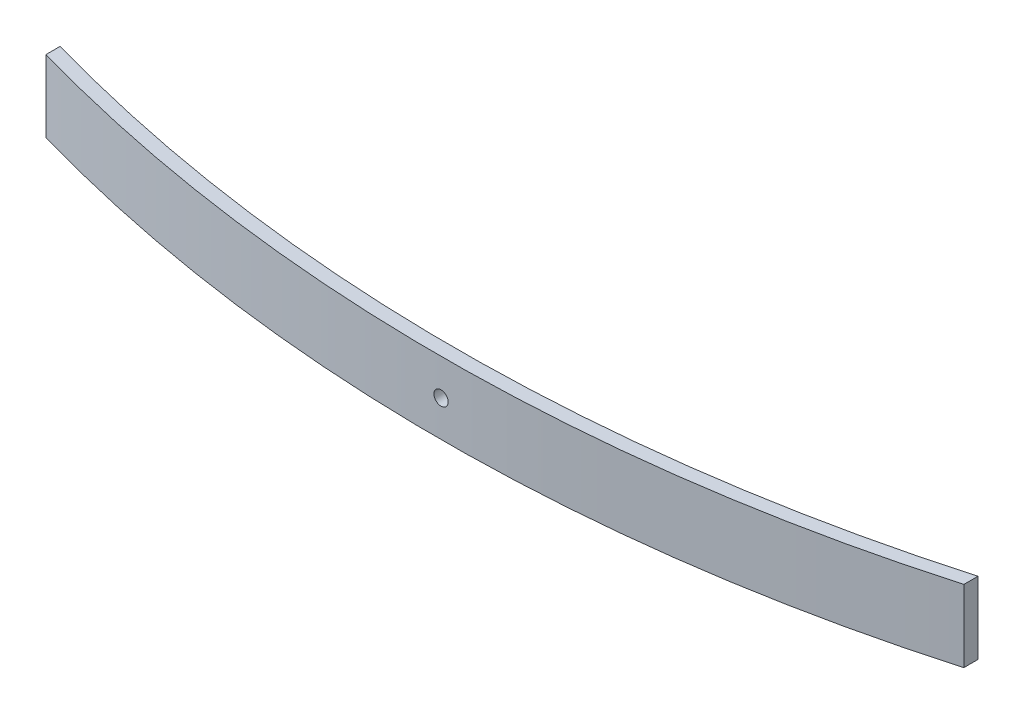
from build123d import *

# Parameters (mm, degrees)
BOSS_EXTRUDE1_DEPTH = 76.2
SKETCH9_R           = 7.5
CUT_EXTRUDE1_DEPTH  = 209


with BuildPart() as part:
    # Sketch1 → Boss-Extrude1 (new body)
    with BuildSketch(Plane(origin=(0, 0, 0), x_dir=(1, 0, 0), z_dir=(0, 1, 0))):
        with BuildLine():
            ThreePointArc((485.021699517, -125.489595812), (0, -193), (-485.021699517, -125.489595812))
            Line((-485.021699517, -125.489595812), (-485.021699517, -140.489595812))
            ThreePointArc((-485.021699517, -140.489595812), (0, -208), (485.021699517, -140.489595812))
            Line((485.021699517, -140.489595812), (485.021699517, -125.489595812))
        make_face()
    extrude(amount=BOSS_EXTRUDE1_DEPTH)

    # Sketch9 → Cut-Extrude1 (cut, through all)
    with BuildSketch(Plane.XY):
        with Locations((0, 38.1)):
            Circle(SKETCH9_R)
    extrude(amount=CUT_EXTRUDE1_DEPTH, mode=Mode.SUBTRACT)


solid = part.part
